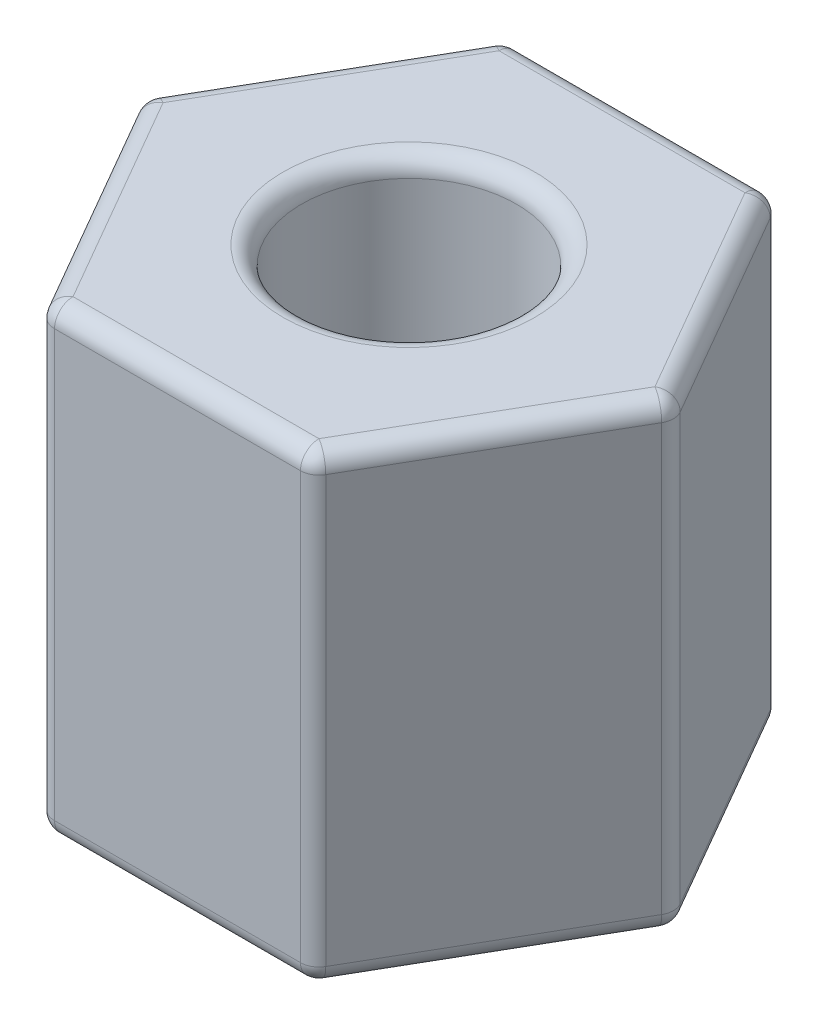
from build123d import *

# Parameters (mm, degrees)
SKETCH1_R           = 1.4732
BOSS_EXTRUDE1_DEPTH = 6.35
FILLET1_R           = 0.254


with BuildPart() as part:
    # Sketch1 → Boss-Extrude1 (new body)
    with BuildSketch(Plane(origin=(0, 0, 0), x_dir=(1, 0, 0), z_dir=(0, 1, 0))):
        Polygon((1.833087105, -3.175), (3.666174209, 0), (1.833087105, 3.175), (-1.833087105, 3.175), (-3.666174209, 0), (-1.833087105, -3.175), align=None)
        Circle(SKETCH1_R, mode=Mode.SUBTRACT)
    extrude(amount=BOSS_EXTRUDE1_DEPTH)

    # Fillet1
    fillet1_edges = [part.edges().sort_by_distance(p)[0] for p in [
        (2.749630657, 6.35, -1.5875),
        (-1.833087105, 3.175, 3.175),
        (-3.666174209, 3.175, 0),
        (-1.833087105, 3.175, -3.175),
        (1.833087105, 3.175, -3.175),
        (3.666174209, 3.175, 0),
        (1.833087105, 3.175, 3.175),
        (0, 6.35, -3.175),
        (-2.749630657, 6.35, -1.5875),
        (-1.4732, 0, 0),
        (-1.4732, 6.35, 0),
        (-2.749630657, 6.35, 1.5875),
        (0, 6.35, 3.175),
        (-2.749630657, 0, 1.5875),
        (-2.749630657, 0, -1.5875),
        (0, 0, -3.175),
        (2.749630657, 6.35, 1.5875),
        (2.749630657, 0, -1.5875),
        (2.749630657, 0, 1.5875),
        (0, 0, 3.175),
    ]]
    fillet(fillet1_edges, radius=FILLET1_R)


solid = part.part
